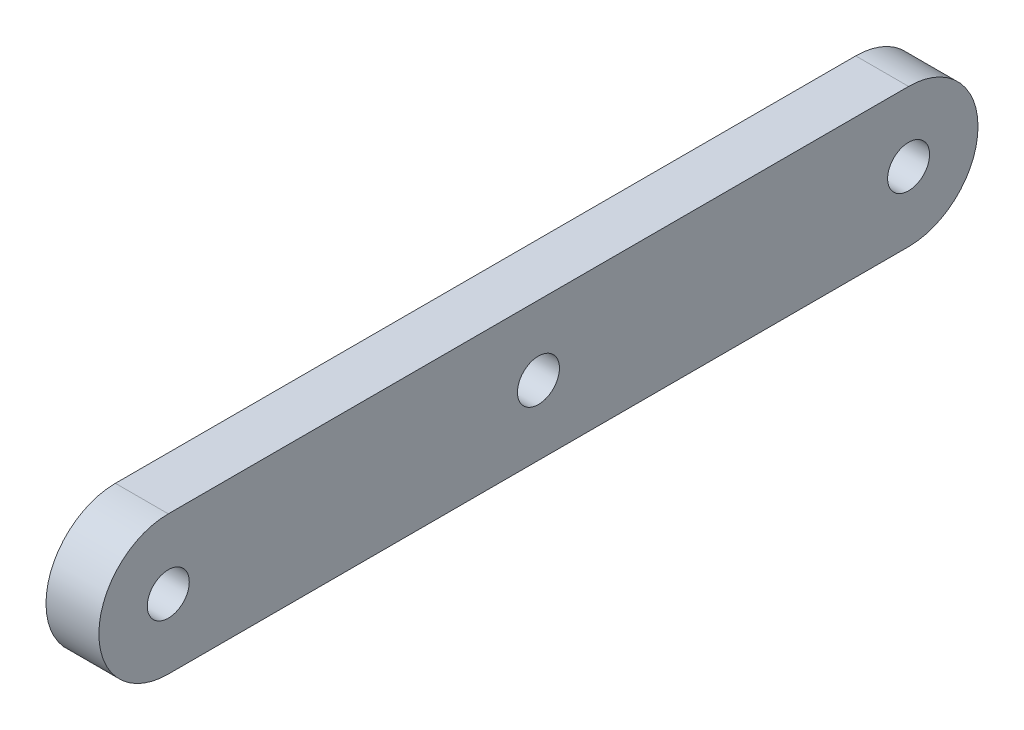
from build123d import *

# Parameters (mm, degrees)
SKETCH1_R                   = 16.66875
BOSS_EXTRUDE1_DEPTH         = 12.7
F_3_8_CLEARANCE_HOLE1_D     = 10.0838
F_3_8_CLEARANCE_HOLE1_DEPTH = 12.7
F_3_8_CLEARANCE_HOLE1_TIP   = 3.029479155


with BuildPart() as part:
    # Sketch1 → Boss-Extrude1 (new body)
    with BuildSketch(Plane(origin=(0, 0, 0), x_dir=(0, 0, -1), z_dir=(1, 0, 0))):
        with Locations((-88.9, 0)):
            Circle(SKETCH1_R)
        with BuildLine():
            Line((88.9, 16.66875), (-88.9, 16.66875))
            ThreePointArc((-88.9, 16.66875), (-77.113413841, 11.786586159), (-72.23125, 0))
            ThreePointArc((-72.23125, 0), (-77.113413841, -11.786586159), (-88.9, -16.66875))
            Line((-88.9, -16.66875), (88.9, -16.66875))
            ThreePointArc((88.9, -16.66875), (72.23125, 0), (88.9, 16.66875))
        make_face()
        with BuildLine():
            ThreePointArc((105.56875, 0), (100.686586159, 11.786586159), (88.9, 16.66875))
            Line((88.9, 16.66875), (88.9, -16.66875))
            ThreePointArc((88.9, -16.66875), (100.686586159, -11.786586159), (105.56875, 0))
        make_face()
        with BuildLine():
            Line((88.9, -16.66875), (88.9, 16.66875))
            ThreePointArc((88.9, 16.66875), (72.23125, 0), (88.9, -16.66875))
        make_face()
    extrude(amount=BOSS_EXTRUDE1_DEPTH)

    # 3/8 Clearance Hole1
    with Locations(Plane(origin=(12.7, 0, 0), x_dir=(0, 0, -1), z_dir=(1, 0, 0))):
        with Locations((0, 0), (88.9, 0), (-88.9, 0)):
            Hole(F_3_8_CLEARANCE_HOLE1_D / 2, depth=F_3_8_CLEARANCE_HOLE1_DEPTH)
            with Locations((0, 0, -(F_3_8_CLEARANCE_HOLE1_DEPTH + F_3_8_CLEARANCE_HOLE1_TIP / 2))):  # 118° drill point
                Cone(0, F_3_8_CLEARANCE_HOLE1_D / 2, F_3_8_CLEARANCE_HOLE1_TIP, mode=Mode.SUBTRACT)


solid = part.part
